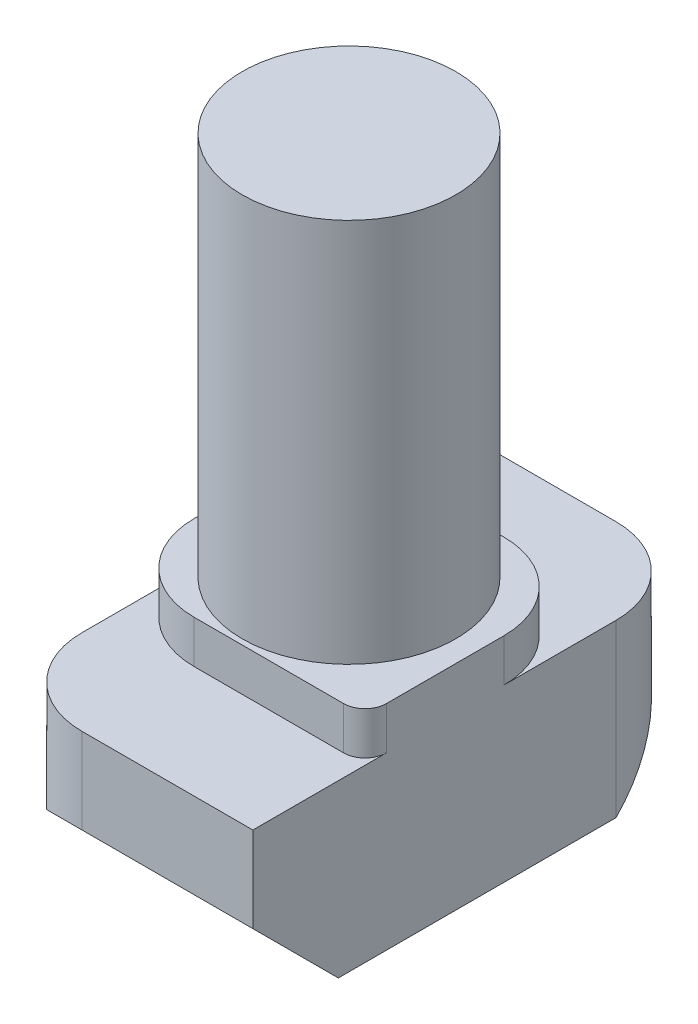
from build123d import *

# Parameters (mm, degrees)
BOSS_EXTRUDE1_DEPTH = 3
FILLET1_R           = 2
FILLET2_R           = 2
FILLET3_R           = 0.5
SKETCH2_W           = 2.5
SKETCH2_H           = 9


with BuildPart() as part:
    # Sketch1 → Boss-Extrude1 (new body, symmetric)
    with BuildSketch(Plane(origin=(0, 0, 0), x_dir=(0, 0, -1), z_dir=(1, 0, 0))):
        Polygon((-2.625, 0), (2.625, 0), (2.625, -1), (5.25, -1), (5.25, -3), (3.25, -5), (-3.25, -5), (-5.25, -3), (-5.25, -1), (-2.625, -1), align=None)
    extrude(amount=BOSS_EXTRUDE1_DEPTH, both=True)

    # Fillet1
    fillet1_edges = [part.edges().sort_by_distance(p)[0] for p in [
        (3, -2, -5.25),
        (-3, -2, 5.25),
    ]]
    fillet(fillet1_edges, radius=FILLET1_R)

    # Fillet2
    fillet2_edges = [part.edges().sort_by_distance(p)[0] for p in [
        (-3, -0.5, 2.625),
        (3, -0.5, -2.625),
    ]]
    fillet(fillet2_edges, radius=FILLET2_R)

    # Fillet3
    fillet3_edges = [part.edges().sort_by_distance(p)[0] for p in [
        (3, -0.5, 2.625),
        (-3, -0.5, -2.625),
    ]]
    fillet(fillet3_edges, radius=FILLET3_R)

    # Sketch2 → Revolve1 (revolve)
    with BuildSketch(Plane.XY):
        with Locations((1.25, 4.5)):
            Rectangle(SKETCH2_W, SKETCH2_H)
    revolve(axis=Axis((0, 55, 0), (0, -1, 0)))


solid = part.part
